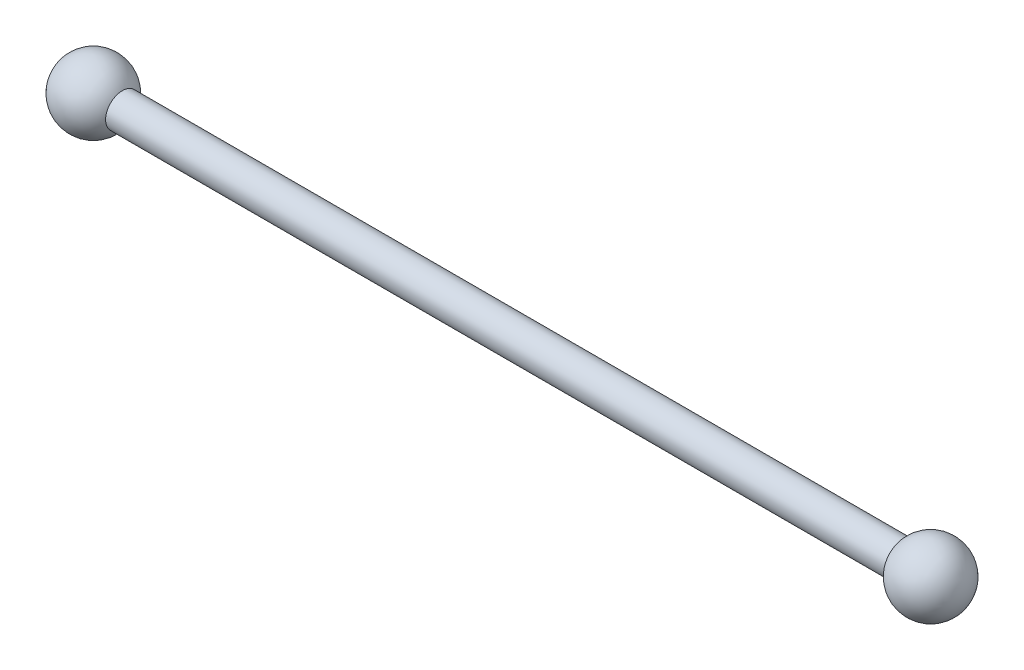
from build123d import *

# Parameters (mm, degrees)
SKETCH1_R           = 5
BOSS_EXTRUDE1_DEPTH = 125


with BuildPart() as part:
    # Sketch1 → Boss-Extrude1 (new body, symmetric)
    with BuildSketch(Plane(origin=(0, 0, 0), x_dir=(0, 0, -1), z_dir=(1, 0, 0))):
        Circle(SKETCH1_R)
    extrude(amount=BOSS_EXTRUDE1_DEPTH, both=True)

    # Sketch2 → Revolve1 (revolve)
    with BuildSketch(Plane(origin=(125, 0, 0), x_dir=(0, 0, -1), z_dir=(1, 0, 0))):
        with BuildLine():
            Line((0, 10), (0, -10))
            ThreePointArc((0, -10), (10, 0), (0, 10))
        make_face()
    revolve1 = revolve(axis=Axis((125, 10, 0), (0, -1, 0)))

    # Mirror1: Revolve1 across plane
    add(revolve1.mirror(Plane(origin=(0, 0, 0), x_dir=(0, 0, 1), z_dir=(1, 0, 0))))


solid = part.part
